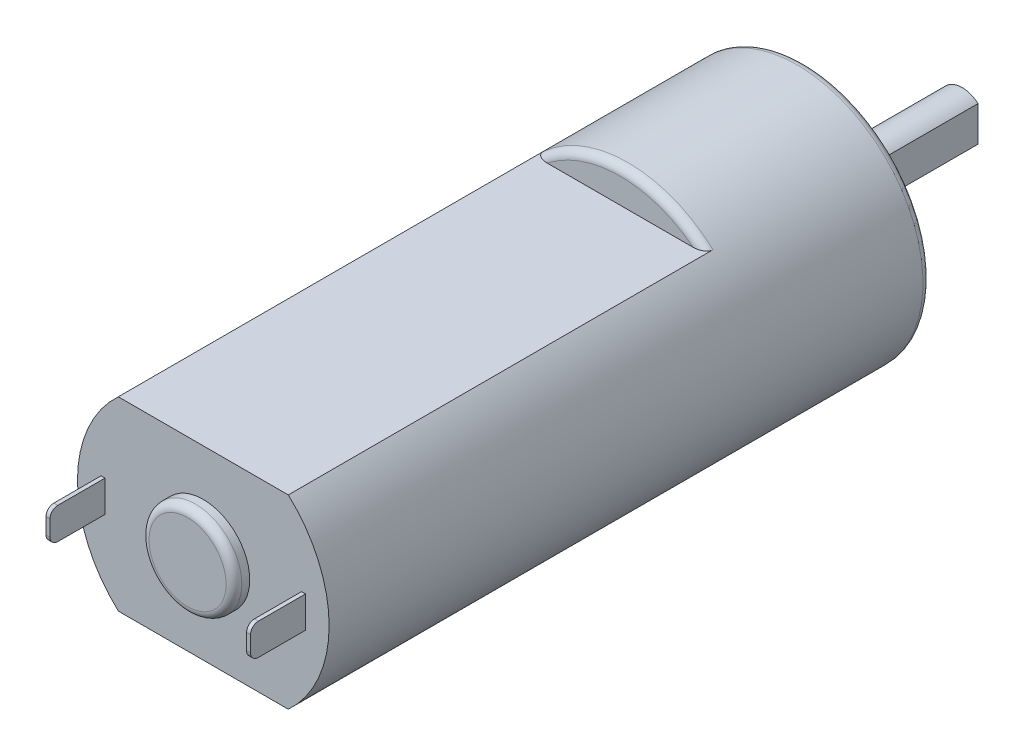
from build123d import *

# Parameters (mm, degrees)
SKETCH1_W           = 8
SKETCH1_H           = 38.25
SKETCH2_R           = 3
BOSS_EXTRUDE1_DEPTH = 2
BOSS_EXTRUDE2_DEPTH = 8
CUT_EXTRUDE1_DEPTH  = 2
CUT_EXTRUDE2_DEPTH  = 26.5
CUT_EXTRUDE3_DEPTH  = 26.5
SKETCH7_W           = 0.25
SKETCH7_H           = 2
BOSS_EXTRUDE3_DEPTH = 3.5
SKETCH8_W           = 0.25
SKETCH8_H           = 2
BOSS_EXTRUDE4_DEPTH = 3.5
SKETCH9_R           = 2.95
BOSS_EXTRUDE5_DEPTH = 1
FILLET1_R           = 0.5


with BuildPart() as part:
    # Sketch1 → Revolve1 (revolve)
    with BuildSketch(Plane.XZ):
        with Locations((4, 19.125)):
            Rectangle(SKETCH1_W, SKETCH1_H)
    revolve(axis=Axis((0, 0, 38.25), (0, 0, -1)))

    # Sketch2 → Boss-Extrude1 (add)
    with BuildSketch(Plane(origin=(0, 0, 0), x_dir=(-1, 0, 0), z_dir=(0, 0, -1))):
        Circle(SKETCH2_R)
    extrude(amount=BOSS_EXTRUDE1_DEPTH)

    # Sketch3 → Boss-Extrude2 (add)
    with BuildSketch(Plane(origin=(0, 0, -2), x_dir=(-1, 0, 0), z_dir=(0, 0, -1))):
        with BuildLine():
            Line((-1, -1.118033989), (-1, 1.118033989))
            ThreePointArc((-1, 1.118033989), (1.5, 0), (-1, -1.118033989))
        make_face()
    extrude(amount=BOSS_EXTRUDE2_DEPTH)

    # Sketch4 → Cut-Extrude1 (cut)
    with BuildSketch(Plane(origin=(0, 0, -2), x_dir=(-1, 0, 0), z_dir=(0, 0, -1))):
        with BuildLine():
            Line((-1, -1.118033989), (-1, 1.118033989))
            ThreePointArc((-1, 1.118033989), (-1.5, 0), (-1, -1.118033989))
        make_face()
    extrude(amount=-CUT_EXTRUDE1_DEPTH, mode=Mode.SUBTRACT)

    # Sketch5 → Cut-Extrude2 (cut)
    with BuildSketch(Plane.XY.offset(38.25)):
        with BuildLine():
            Line((-5.402777064, 5.9), (5.402777064, 5.9))
            ThreePointArc((5.402777064, 5.9), (0, 8), (-5.402777064, 5.9))
        make_face()
    extrude(amount=-CUT_EXTRUDE2_DEPTH, mode=Mode.SUBTRACT)

    # Sketch6 → Cut-Extrude3 (cut)
    with BuildSketch(Plane.XY.offset(38.25)):
        with BuildLine():
            Line((5.402777064, -5.9), (-5.402777064, -5.9))
            ThreePointArc((-5.402777064, -5.9), (0, -8), (5.402777064, -5.9))
        make_face()
    extrude(amount=-CUT_EXTRUDE3_DEPTH, mode=Mode.SUBTRACT)

    # Sketch7 → Boss-Extrude3 (add)
    with BuildSketch(Plane.XY.offset(38.25)):
        with Locations((-6.375, 0)):
            Rectangle(SKETCH7_W, SKETCH7_H)
    extrude(amount=BOSS_EXTRUDE3_DEPTH)

    # Sketch8 → Boss-Extrude4 (add)
    with BuildSketch(Plane.XY.offset(38.25)):
        with Locations((6.375, 0)):
            Rectangle(SKETCH8_W, SKETCH8_H)
    extrude(amount=BOSS_EXTRUDE4_DEPTH)

    # Sketch9 → Boss-Extrude5 (add)
    with BuildSketch(Plane.XY.offset(38.25)):
        Circle(SKETCH9_R)
    extrude(amount=BOSS_EXTRUDE5_DEPTH)

    # Fillet1
    fillet1_edges = [part.edges().sort_by_distance(p)[0] for p in [
        (0, 8, 11.75),
        (0, -8, 11.75),
        (-8, 0, 0),
        (-6.375, -1, 41.75),
        (-6.375, 1, 41.75),
        (6.375, -1, 41.75),
        (6.375, 1, 41.75),
        (-2.95, 0, 39.25),
    ]]
    fillet(fillet1_edges, radius=FILLET1_R)


solid = part.part
